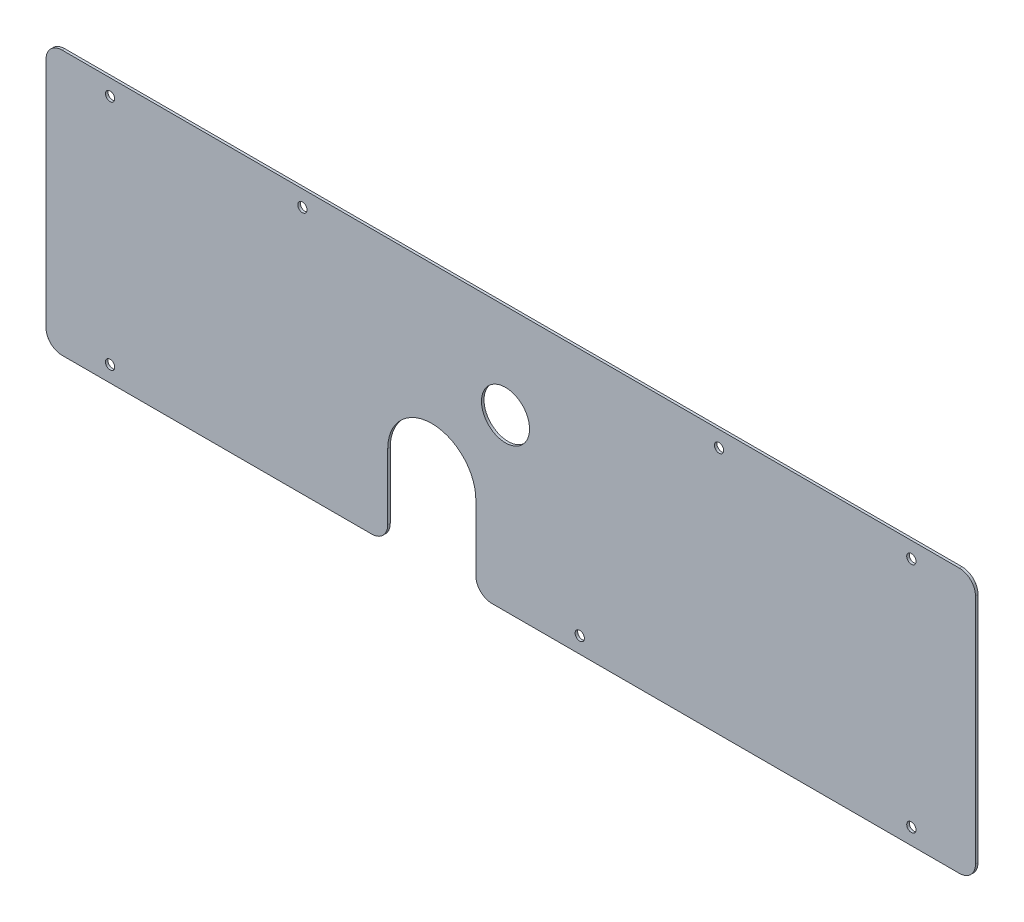
from build123d import *

# Parameters (mm, degrees)
SKETCH1_R            = 15
BOSS_EXTRUDE1_DEPTH  = 1.5875
M5_CLEARANCE_HOLE1_D = 5.8
FILLET1_R            = 10


with BuildPart() as part:
    # Sketch1 → Boss-Extrude1 (new body)
    with BuildSketch(Plane.XY):
        with BuildLine():
            Line((-31.721304871, -10.769995549), (-31.721304871, -61.809795549))
            Line((-31.721304871, -61.809795549), (-244.957511762, -61.809795549))
            Line((-244.957511762, -61.809795549), (-244.957511762, 103.169804451))
            Line((-244.957511762, 103.169804451), (335.042488238, 103.169804451))
            Line((335.042488238, 103.169804451), (335.042488238, -61.809795549))
            Line((335.042488238, -61.809795549), (23.278695129, -61.809795549))
            Line((23.278695129, -61.809795549), (23.278695129, -10.769995549))
            ThreePointArc((23.278695129, -10.769995549), (-4.221304871, 16.730004451), (-31.721304871, -10.769995549))
        make_face()
        with Locations((41.778695129, 44.230004451)):
            Circle(SKETCH1_R, mode=Mode.SUBTRACT)
    extrude(amount=BOSS_EXTRUDE1_DEPTH)

    # M5 Clearance Hole1 (through all)
    with Locations(Plane.XY.offset(1.5875)):
        with Locations((-204.957511762, 93.169804451), (-204.957511762, -51.809795549), (88.121775735, -51.809795549), (295.042488238, -51.809795549), (-84.957511762, 93.169804451), (175.042488238, 93.169804451), (295.042488238, 93.169804451)):
            Hole(M5_CLEARANCE_HOLE1_D / 2)

    # Fillet1
    fillet1_edges = [part.edges().sort_by_distance(p)[0] for p in [
        (-244.957511762, 103.169804451, 0.79375),
        (335.042488238, 103.169804451, 0.79375),
        (335.042488238, -61.809795549, 0.79375),
        (23.278695129, -61.809795549, 0.79375),
        (-31.721304871, -61.809795549, 0.79375),
        (-244.957511762, -61.809795549, 0.79375),
    ]]
    fillet(fillet1_edges, radius=FILLET1_R)


solid = part.part
